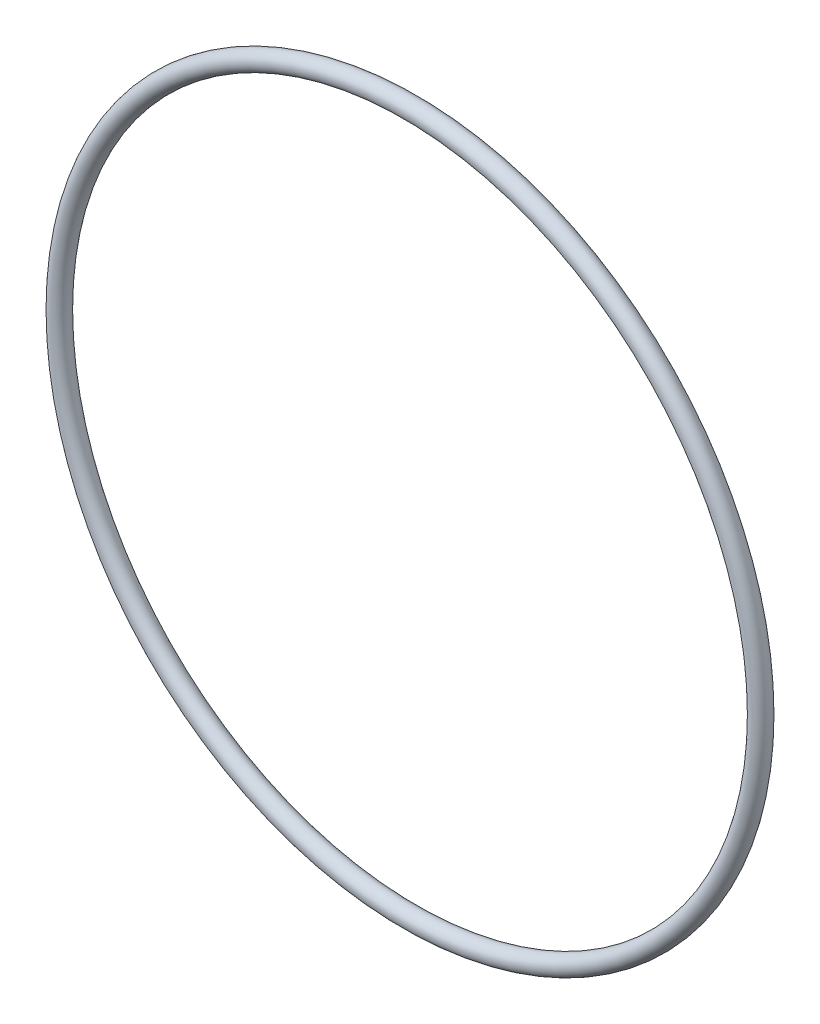
from build123d import *

# Parameters (mm, degrees)
SKETCH1_R = 1.3081


with BuildPart() as part:
    # Sketch1 → Revolve1 (revolve)
    with BuildSketch(Plane(origin=(0, 0, 0), x_dir=(0, -1, 0), z_dir=(1, 0, 0))):
        with Locations((48.768, 0)):
            Circle(SKETCH1_R)
    revolve(axis=Axis((0, 0, 1.3081), (0, 0, -1)))


solid = part.part
